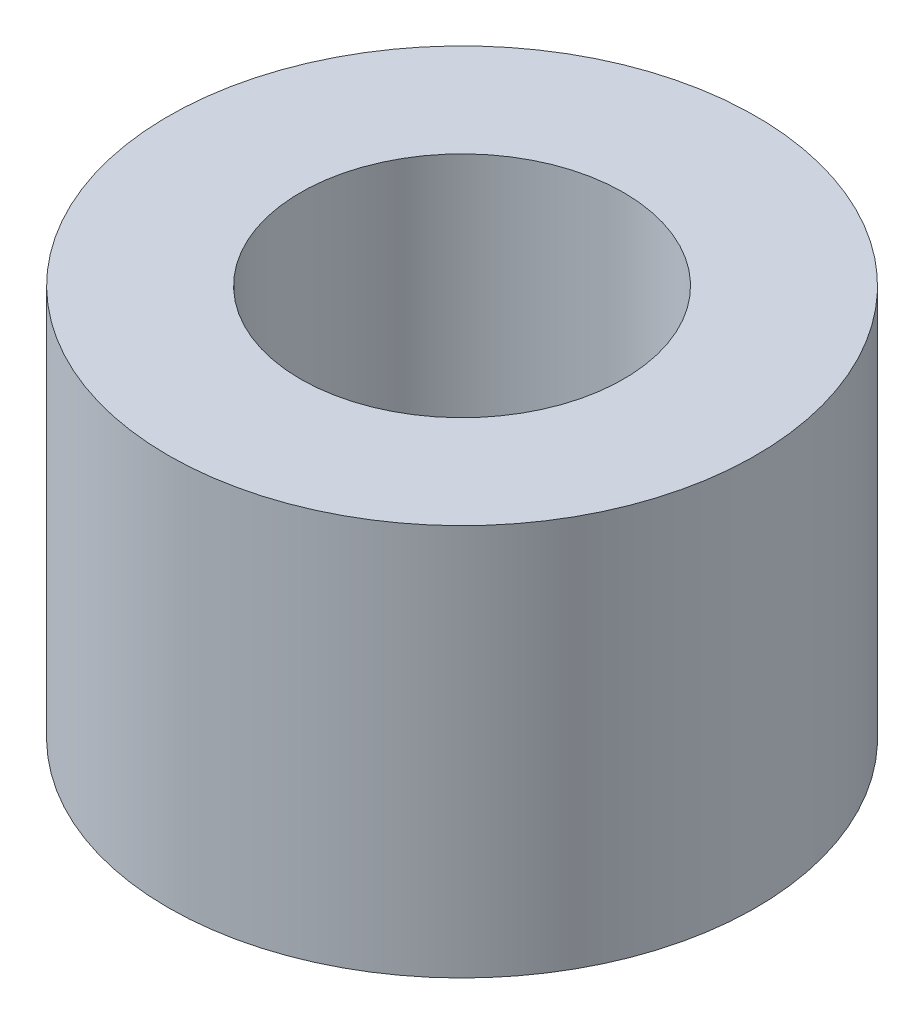
from build123d import *

# Parameters (mm, degrees)
SKETCH1_R           = 3
SKETCH1_R_2         = 1.65
BOSS_EXTRUDE1_DEPTH = 4


with BuildPart() as part:
    # Sketch1 → Boss-Extrude1 (new body)
    with BuildSketch(Plane(origin=(0, 0, 0), x_dir=(1, 0, 0), z_dir=(0, 1, 0))):
        Circle(SKETCH1_R)
        Circle(SKETCH1_R_2, mode=Mode.SUBTRACT)
    extrude(amount=BOSS_EXTRUDE1_DEPTH)


solid = part.part
